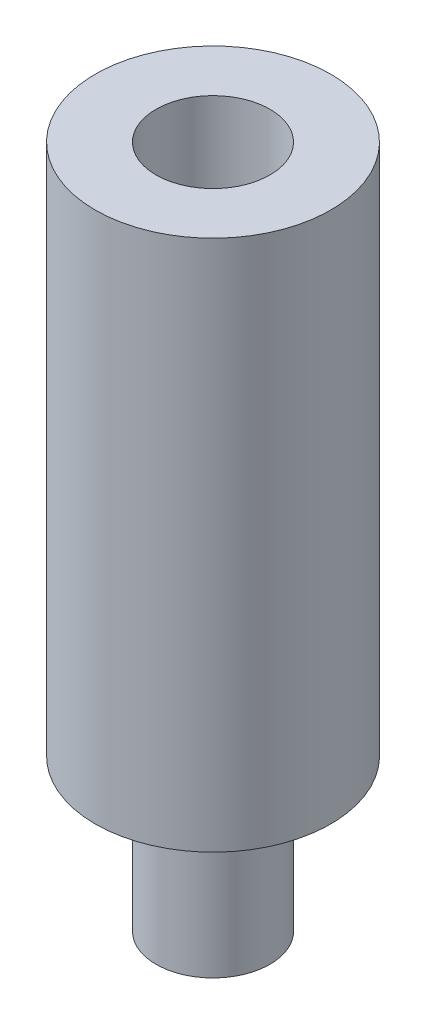
from build123d import *

# Parameters (mm, degrees)
SKETCH1_R           = 3.1
BOSS_EXTRUDE1_DEPTH = 14
SKETCH2_R           = 1.5
CUT_EXTRUDE1_DEPTH  = 5
SKETCH3_R           = 1.5
BOSS_EXTRUDE2_DEPTH = 4


with BuildPart() as part:
    # Sketch1 → Boss-Extrude1 (new body)
    with BuildSketch(Plane(origin=(0, 0, 0), x_dir=(1, 0, 0), z_dir=(0, 1, 0))):
        Circle(SKETCH1_R)
    extrude(amount=BOSS_EXTRUDE1_DEPTH)

    # Sketch2 → Cut-Extrude1 (cut)
    with BuildSketch(Plane(origin=(0, 14, 0), x_dir=(1, 0, 0), z_dir=(0, 1, 0))):
        Circle(SKETCH2_R)
    extrude(amount=-CUT_EXTRUDE1_DEPTH, mode=Mode.SUBTRACT)

    # Sketch3 → Boss-Extrude2 (add)
    with BuildSketch(Plane.XZ):
        Circle(SKETCH3_R)
    extrude(amount=BOSS_EXTRUDE2_DEPTH)


solid = part.part
